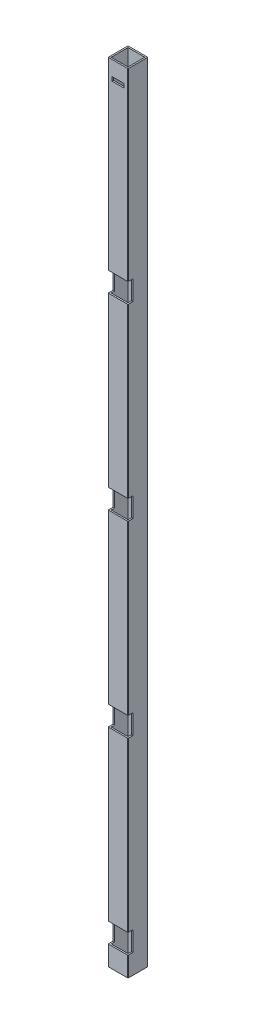
from build123d import *

# Parameters (mm, degrees)
SKETCH1_W           = 17
SKETCH1_H           = 17
BOSS_EXTRUDE1_DEPTH = 796.5
SKETCH3_W           = 12
SKETCH3_H           = 4
CUT_EXTRUDE1_DEPTH  = 10
SKETCH5_W           = 5
SKETCH5_H           = 20
CUT_EXTRUDE2_DEPTH  = 798.002038893


with BuildPart() as part:
    # Sketch1 → Boss-Extrude1 (new body)
    with BuildSketch(Plane(origin=(0, 0, 0), x_dir=(1, 0, 0), z_dir=(0, 1, 0))):
        with BuildLine():
            Line((0.5, 0), (19.5, 0))
            ThreePointArc((19.5, 0), (19.853553391, 0.146446609), (20, 0.5))
            Line((20, 0.5), (20, 19.5))
            ThreePointArc((20, 19.5), (19.853553391, 19.853553391), (19.5, 20))
            Line((19.5, 20), (0.5, 20))
            ThreePointArc((0.5, 20), (0.146446609, 19.853553391), (0, 19.5))
            Line((0, 19.5), (0, 0.5))
            ThreePointArc((0, 0.5), (0.146446609, 0.146446609), (0.5, 0))
        make_face()
        with Locations((10, 10)):
            Rectangle(SKETCH1_W, SKETCH1_H, mode=Mode.SUBTRACT)
    extrude(amount=BOSS_EXTRUDE1_DEPTH)

    # Sketch3 → Cut-Extrude1 (cut)
    with BuildSketch(Plane.XY):
        with Locations((10, 779.5)):
            Rectangle(SKETCH3_W, SKETCH3_H)
    extrude(amount=-CUT_EXTRUDE1_DEPTH, mode=Mode.SUBTRACT)

    # Sketch5 → Cut-Extrude2 (cut, through all)
    with BuildSketch(Plane.ZY):
        with Locations((-2.5, 600)):
            Rectangle(SKETCH5_W, SKETCH5_H)
        with Locations((-2.5, 410)):
            Rectangle(SKETCH5_W, SKETCH5_H)
        with Locations((-2.5, 220)):
            Rectangle(SKETCH5_W, SKETCH5_H)
        with Locations((-2.5, 30)):
            Rectangle(SKETCH5_W, SKETCH5_H)
    extrude(amount=-CUT_EXTRUDE2_DEPTH, mode=Mode.SUBTRACT)


solid = part.part
